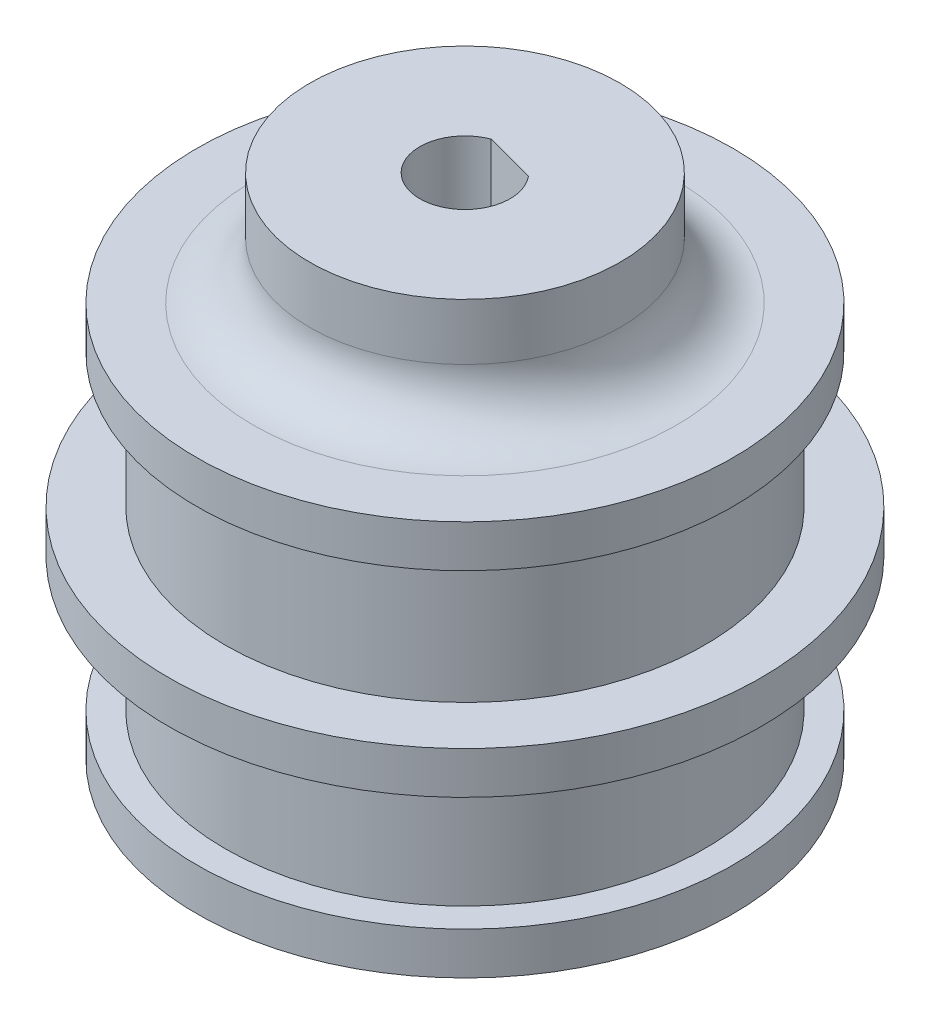
from build123d import *

# Parameters (mm, degrees)
ZAOKR_GLENIE1_R            = 2
WYTNIJ_WYCI_GNI_CIE1_DEPTH = 19


with BuildPart() as part:
    # Szkic1 → Obrót1 (revolve)
    with BuildSketch(Plane.XY):
        with BuildLine():
            Line((7.5, -4.799176992), (7.5, 0.200823008))
            ThreePointArc((7.5, 0.200823008), (6.328427125, 3.029250132), (3.5, 4.200823008))
            Line((3.5, 4.200823008), (0, 4.200823008))
            Line((0, 4.200823008), (0, 13.200823008))
            Line((0, 13.200823008), (5.5, 13.200823008))
            Line((5.5, 13.200823008), (5.5, 9.200823008))
            Line((5.5, 9.200823008), (9.5, 9.200823008))
            Line((9.5, 9.200823008), (9.5, 7.700823008))
            Line((9.5, 7.700823008), (8.5, 7.700823008))
            Line((8.5, 7.700823008), (8.5, 2.950823008))
            Line((8.5, 2.950823008), (10.5, 2.950823008))
            Line((10.5, 2.950823008), (10.5, 1.450823008))
            Line((10.5, 1.450823008), (8.5, 1.450823008))
            Line((8.5, 1.450823008), (8.5, -3.299176992))
            Line((8.5, -3.299176992), (9.5, -3.299176992))
            Line((9.5, -3.299176992), (9.5, -4.799176992))
            Line((9.5, -4.799176992), (7.5, -4.799176992))
        make_face()
    revolve(axis=Axis((0, -15.783107462, 0), (0, 1, 0)))

    # Zaokrąglenie1
    zaokr_glenie1_edges = [part.edges().sort_by_distance(p)[0] for p in [
        (-5.5, 9.200823008, 0),
    ]]
    fillet(zaokr_glenie1_edges, radius=ZAOKR_GLENIE1_R)

    # Szkic2 → Wytnij-wyciągnięcie1 (cut, through all)
    with BuildSketch(Plane(origin=(0, 13.200823008, 0), x_dir=(1, 0, 0), z_dir=(0, 1, 0))):
        with BuildLine():
            Line((-0.568761348, 1.49549675), (1.234520551, 1.017820716))
            ThreePointArc((1.234520551, 1.017820716), (-0.409697971, -1.546656902), (-0.568761348, 1.49549675))
        make_face()
    extrude(amount=-WYTNIJ_WYCI_GNI_CIE1_DEPTH, mode=Mode.SUBTRACT)


solid = part.part
